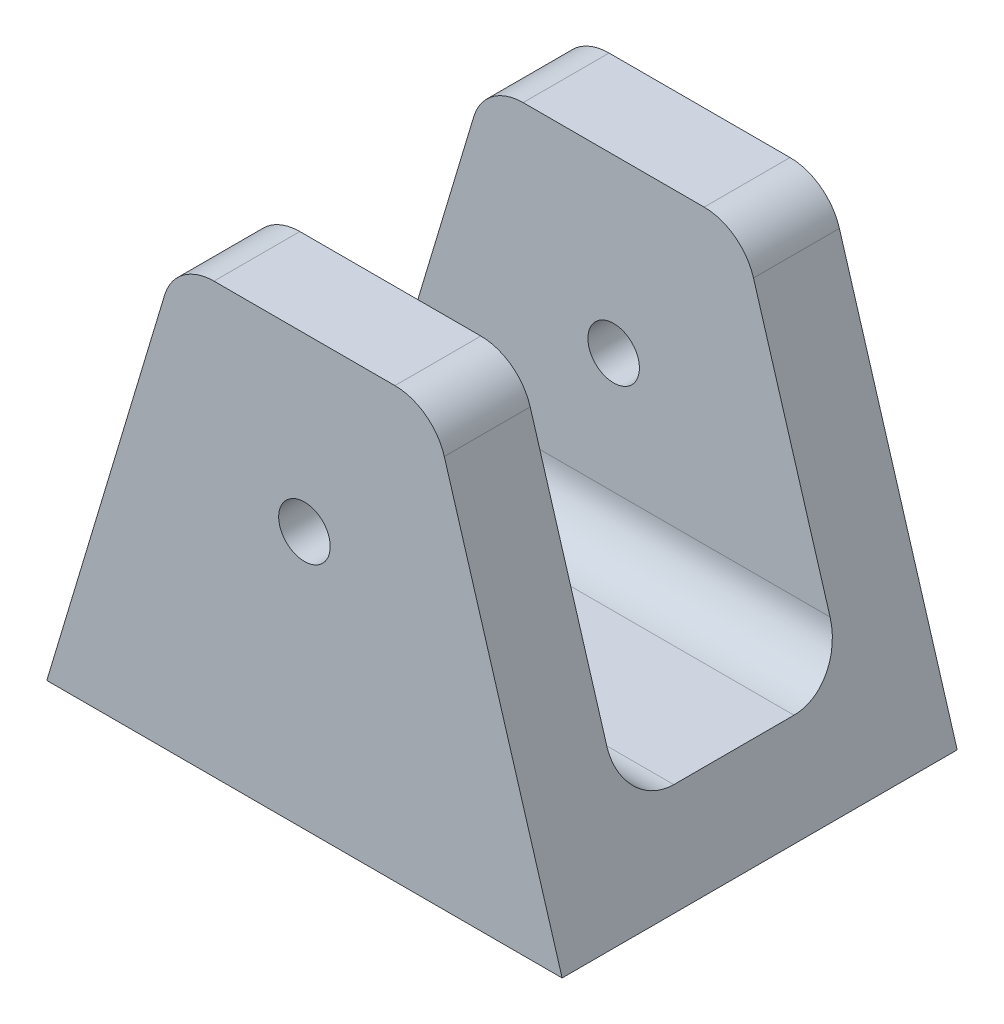
from build123d import *

# Parameters (mm, degrees)
SKETCH1_R               = 1.5
BOSS_EXTRUDE1_DEPTH     = 23
SKETCH2_W               = 13
SKETCH2_H               = 23.129290295
CUT_EXTRUDE1_DEPTH      = 16
CUT_EXTRUDE1_DEPTH_BACK = 16
FILLET1_R               = 3
SKETCH3_R               = 1.5
CUT_EXTRUDE2_DEPTH      = 6


with BuildPart() as part:
    # Sketch1 → Boss-Extrude1 (new body)
    with BuildSketch(Plane.XY):
        with BuildLine():
            Line((-15, 0), (15, 0))
            Line((15, 0), (8.141386903, 22.862043657))
            ThreePointArc((8.141386903, 22.862043657), (7.058699636, 24.406878785), (5.267908047, 25))
            Line((5.267908047, 25), (-5.267908047, 25))
            ThreePointArc((-5.267908047, 25), (-7.058699636, 24.406878785), (-8.141386903, 22.862043657))
            Line((-8.141386903, 22.862043657), (-15, 0))
        make_face()
        with Locations((0, 15)):
            Circle(SKETCH1_R, mode=Mode.SUBTRACT)
    extrude(amount=BOSS_EXTRUDE1_DEPTH)

    # Sketch2 → Cut-Extrude1 (cut, two sides)
    with BuildSketch(Plane(origin=(0, 0, 0), x_dir=(0, 0, -1), z_dir=(1, 0, 0))) as cut_extrude1_sk:
        with Locations((-11.5, 16.564645148)):
            Rectangle(SKETCH2_W, SKETCH2_H)
    extrude(amount=CUT_EXTRUDE1_DEPTH, mode=Mode.SUBTRACT)
    extrude(cut_extrude1_sk.sketch, amount=-CUT_EXTRUDE1_DEPTH_BACK, mode=Mode.SUBTRACT)

    # Fillet1
    fillet1_edges = [part.edges().sort_by_distance(p)[0] for p in [
        (0, 5, 5),
        (0, 5, 18),
    ]]
    fillet(fillet1_edges, radius=FILLET1_R)

    # Sketch3 → Cut-Extrude2 (cut, through all)
    with BuildSketch(Plane(origin=(0, 5, 0), x_dir=(1, 0, 0), z_dir=(0, 1, 0))):
        with Locations((0, -11.5)):
            Circle(SKETCH3_R)
    extrude(amount=-CUT_EXTRUDE2_DEPTH, mode=Mode.SUBTRACT)


solid = part.part
